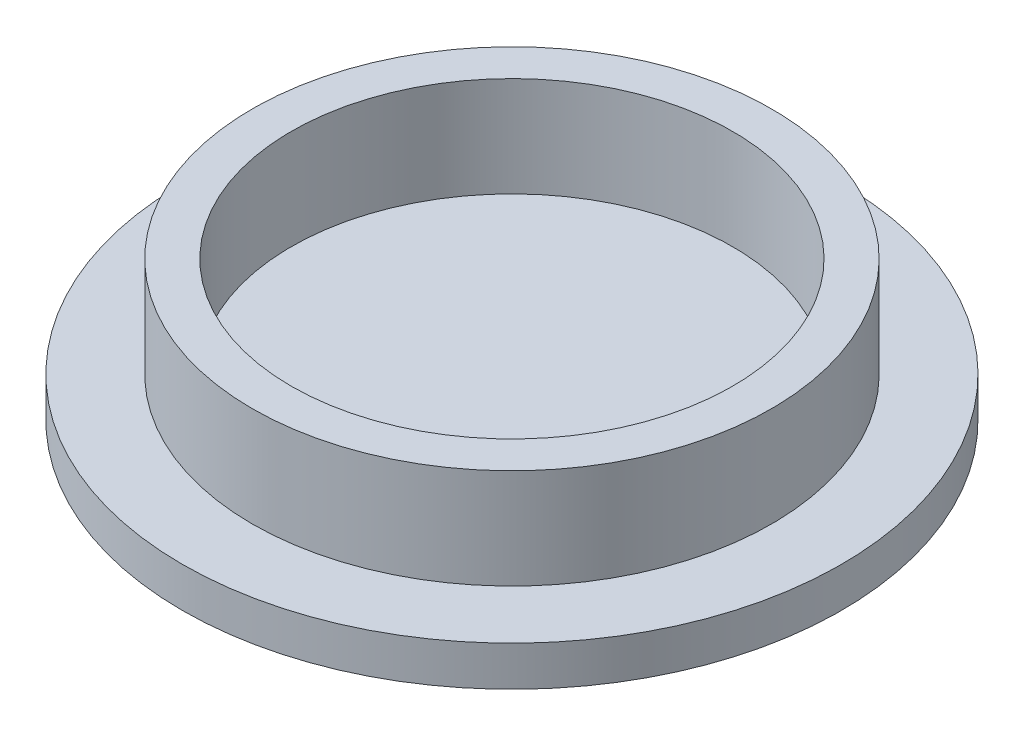
from build123d import *

# Parameters (mm, degrees)
CROQUIS1_R              = 16.5
SALIENTE_EXTRUIR1_DEPTH = 2
CROQUIS2_R              = 13
CROQUIS2_R_2            = 11.05
SALIENTE_EXTRUIR2_DEPTH = 5


with BuildPart() as part:
    # Croquis1 → Saliente-Extruir1 (new body)
    with BuildSketch(Plane(origin=(0, 0, 0), x_dir=(1, 0, 0), z_dir=(0, 1, 0))):
        Circle(CROQUIS1_R)
    extrude(amount=SALIENTE_EXTRUIR1_DEPTH)

    # Croquis2 → Saliente-Extruir2 (add)
    with BuildSketch(Plane(origin=(0, 2, 0), x_dir=(1, 0, 0), z_dir=(0, 1, 0))):
        Circle(CROQUIS2_R)
        Circle(CROQUIS2_R_2, mode=Mode.SUBTRACT)
    extrude(amount=SALIENTE_EXTRUIR2_DEPTH)


solid = part.part
